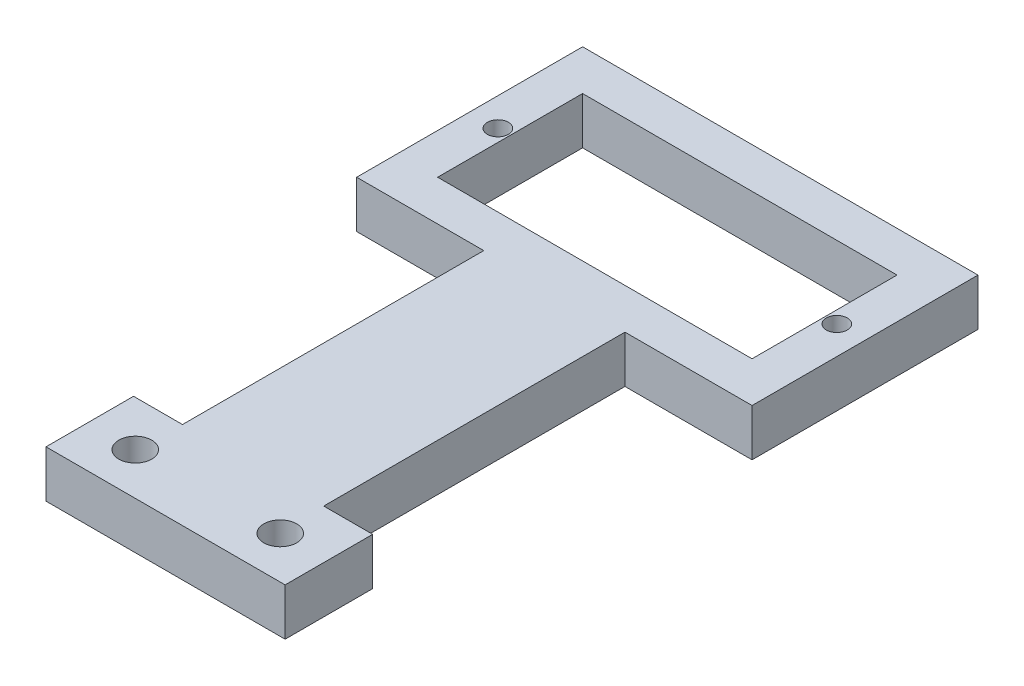
from build123d import *

# Parameters (mm, degrees)
SKETCH1_W           = 42
SKETCH1_H           = 24
BOSS_EXTRUDE1_DEPTH = 5
SKETCH2_W           = 33.4
SKETCH2_H           = 15.4
CUT_EXTRUDE1_DEPTH  = 6
SKETCH3_W           = 15
SKETCH3_H           = 32
BOSS_EXTRUDE2_DEPTH = 5
SKETCH4_W           = 25.4
SKETCH4_H           = 9.3
BOSS_EXTRUDE3_DEPTH = 5
SKETCH5_R           = 1.75
CUT_EXTRUDE2_DEPTH  = 6
SKETCH6_R           = 1.115
CUT_EXTRUDE3_DEPTH  = 6


with BuildPart() as part:
    # Sketch1 → Boss-Extrude1 (new body)
    with BuildSketch(Plane(origin=(0, 0, 0), x_dir=(1, 0, 0), z_dir=(0, 1, 0))):
        with Locations((21, 12)):
            Rectangle(SKETCH1_W, SKETCH1_H)
    extrude(amount=BOSS_EXTRUDE1_DEPTH)

    # Sketch2 → Cut-Extrude1 (cut, through all)
    with BuildSketch(Plane(origin=(0, 5, 0), x_dir=(1, 0, 0), z_dir=(0, 1, 0))):
        with Locations((21, 12)):
            Rectangle(SKETCH2_W, SKETCH2_H)
    extrude(amount=-CUT_EXTRUDE1_DEPTH, mode=Mode.SUBTRACT)

    # Sketch3 → Boss-Extrude2 (add)
    with BuildSketch(Plane(origin=(0, 5, 0), x_dir=(1, 0, 0), z_dir=(0, 1, 0))):
        with Locations((21, -16)):
            Rectangle(SKETCH3_W, SKETCH3_H)
    extrude(amount=-BOSS_EXTRUDE2_DEPTH)

    # Sketch4 → Boss-Extrude3 (add)
    with BuildSketch(Plane(origin=(0, 5, 0), x_dir=(1, 0, 0), z_dir=(0, 1, 0))):
        with Locations((21, -36.65)):
            Rectangle(SKETCH4_W, SKETCH4_H)
    extrude(amount=-BOSS_EXTRUDE3_DEPTH)

    # Sketch5 → Cut-Extrude2 (cut, through all)
    with BuildSketch(Plane(origin=(0, 5, 0), x_dir=(1, 0, 0), z_dir=(0, 1, 0))):
        with Locations((13.3, -36.81777032)):
            Circle(SKETCH5_R)
        with Locations((28.7, -36.81777032)):
            Circle(SKETCH5_R)
    extrude(amount=-CUT_EXTRUDE2_DEPTH, mode=Mode.SUBTRACT)

    # Sketch6 → Cut-Extrude3 (cut, through all)
    with BuildSketch(Plane(origin=(0, 5, 0), x_dir=(1, 0, 0), z_dir=(0, 1, 0))):
        with Locations((3, 12)):
            Circle(SKETCH6_R)
        with Locations((39, 12)):
            Circle(SKETCH6_R)
    extrude(amount=-CUT_EXTRUDE3_DEPTH, mode=Mode.SUBTRACT)


solid = part.part
